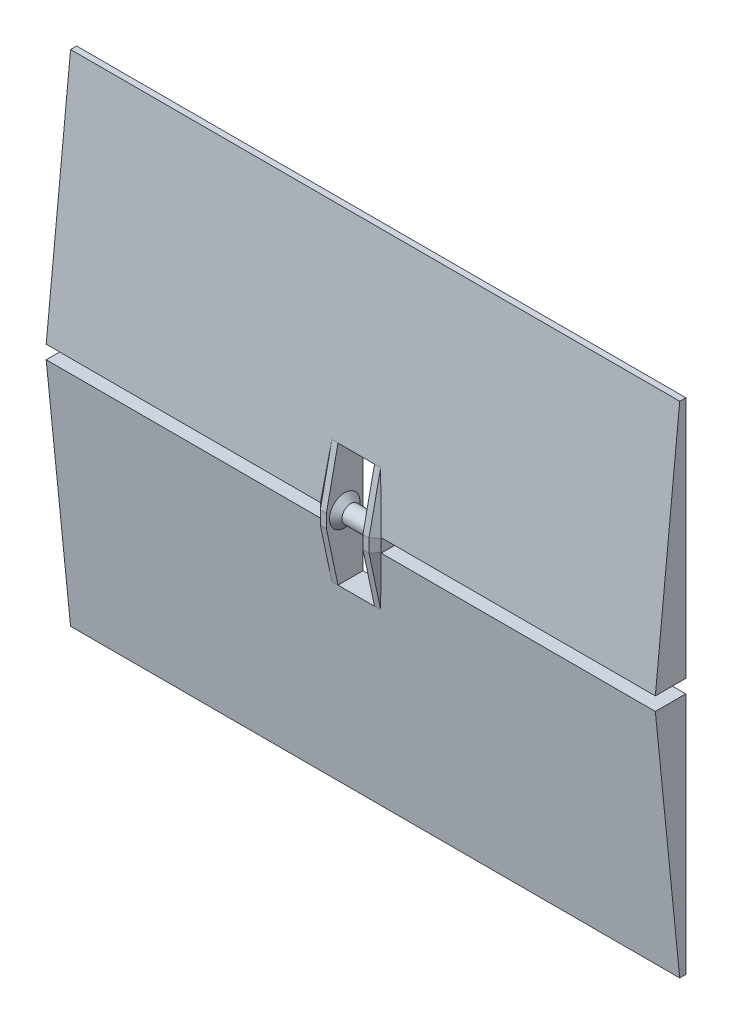
from build123d import *

# Parameters (mm, degrees)
DODANIE_WYCI_GNI_CIE1_DEPTH = 1
DODANIE_WYCI_GNI_CIE2_DEPTH = 100
SZKIC3_W                    = 6
SZKIC3_H                    = 9
WYTNIJ_WYCI_GNI_CIE1_DEPTH  = 10
SZKIC4_W                    = 2
SZKIC4_H                    = 5
DODANIE_WYCI_GNI_CIE3_DEPTH = 1.1
DODANIE_WYCI_GNI_CIE5_DEPTH = 2
SZKIC8_R                    = 2.5
SZKIC9_R                    = 1.45
SZKIC10_R                   = 1.45
DODANIE_WYCI_GNI_CIE6_DEPTH = 2
SFAZOWANIE1_SIZE            = 1


with BuildPart() as part:
    # Szkic1 → Dodanie-wyciągnięcie1 (new body)
    with BuildSketch(Plane.XY):
        Polygon((15.316574048, 11.214895549), (-29.683425952, 11.214895549), (-29.683425952, -28.685104451), (70.316574048, -28.685104451), (70.316574048, 11.214895549), (25.316574048, 11.214895549), align=None)
    extrude(amount=DODANIE_WYCI_GNI_CIE1_DEPTH)

    # Szkic2 → Dodanie-wyciągnięcie2 (add)
    with BuildSketch(Plane.ZY.offset(29.683425952)):
        Polygon((1, 11.214895549), (5, 11.214895549), (1, -28.685104451), align=None)
    extrude(amount=-DODANIE_WYCI_GNI_CIE2_DEPTH)

    # Szkic3 → Wytnij-wyciągnięcie1 (cut)
    with BuildSketch(Plane(origin=(0, 0, 0), x_dir=(-1, 0, 0), z_dir=(0, 0, -1))):
        with Locations((-20.316574048, 6.714895549)):
            Rectangle(SZKIC3_W, SZKIC3_H)
    extrude(amount=-WYTNIJ_WYCI_GNI_CIE1_DEPTH, mode=Mode.SUBTRACT)

    # Szkic4 → Dodanie-wyciągnięcie3 (add)
    with BuildSketch(Plane(origin=(0, 11.214895549, 0), x_dir=(1, 0, 0), z_dir=(0, 1, 0))):
        with Locations((24.316574048, -2.5)):
            Rectangle(SZKIC4_W, SZKIC4_H)
        with Locations((16.316574048, -2.5)):
            Rectangle(SZKIC4_W, SZKIC4_H)
    extrude(amount=DODANIE_WYCI_GNI_CIE3_DEPTH)

    # Lustro2: part across plane


with BuildPart() as part_1:
    add(part.part)
    add(part.part.mirror(Plane.ZX.offset(12.314895549)))

    # Szkic7 → Dodanie-wyciągnięcie5 (add)
    with BuildSketch(Plane.ZY.offset(-23.316574048)):
        Polygon((4.097744361, 22.414895549), (5, 13.414895549), (5, 11.214895549), (4.097744361, 2.214895549), (6, 11.214895549), (6, 13.414895549), align=None)
    dodanie_wyci_gni_cie5 = extrude(amount=-DODANIE_WYCI_GNI_CIE5_DEPTH)

    # Szkic8 → Wyciągnięcie po profilach1 section 0
    with BuildSketch(Plane.ZY.offset(-23.316574048)):
        with Locations((3, 12.314895549)):
            Circle(SZKIC8_R)
    # Szkic9 → Wyciągnięcie po profilach1 section 1
    with BuildSketch(Plane.ZY.offset(-22.316574048)):
        with Locations((3, 12.314895549)):
            Circle(SZKIC9_R)
    wyci_gni_cie_po_profilach1 = loft()

    # Szkic10 → Dodanie-wyciągnięcie6 (add)
    with BuildSketch(Plane.ZY.offset(-22.316574048)):
        with Locations((3, 12.314895549)):
            Circle(SZKIC10_R)
    dodanie_wyci_gni_cie6 = extrude(amount=DODANIE_WYCI_GNI_CIE6_DEPTH)

    # Lustro3: Dodanie-wyciągnięcie5, Wyciągnięcie po profilach1, Dodanie-wyciągnięcie6 across plane
    add(dodanie_wyci_gni_cie5.mirror(Plane(origin=(20.316574048, 12.314895549, 3), x_dir=(0, 0, 1), z_dir=(-1, 0, 0))))
    add(wyci_gni_cie_po_profilach1.mirror(Plane(origin=(20.316574048, 12.314895549, 3), x_dir=(0, 0, 1), z_dir=(-1, 0, 0))))
    add(dodanie_wyci_gni_cie6.mirror(Plane(origin=(20.316574048, 12.314895549, 3), x_dir=(0, 0, 1), z_dir=(-1, 0, 0))))

    # Sfazowanie1
    sfazowanie1_edges = [part_1.edges().sort_by_distance(p)[0] for p in [
        (15.316574048, 6.714895549, 5.04887218),
        (15.316574048, 12.314895549, 6),
        (15.316574048, 17.914895549, 5.04887218),
        (25.316574048, 17.914895549, 5.04887218),
        (25.316574048, 12.314895549, 6),
        (25.316574048, 6.714895549, 5.04887218),
    ]]
    chamfer(sfazowanie1_edges, length=SFAZOWANIE1_SIZE)


solid = part_1.part
